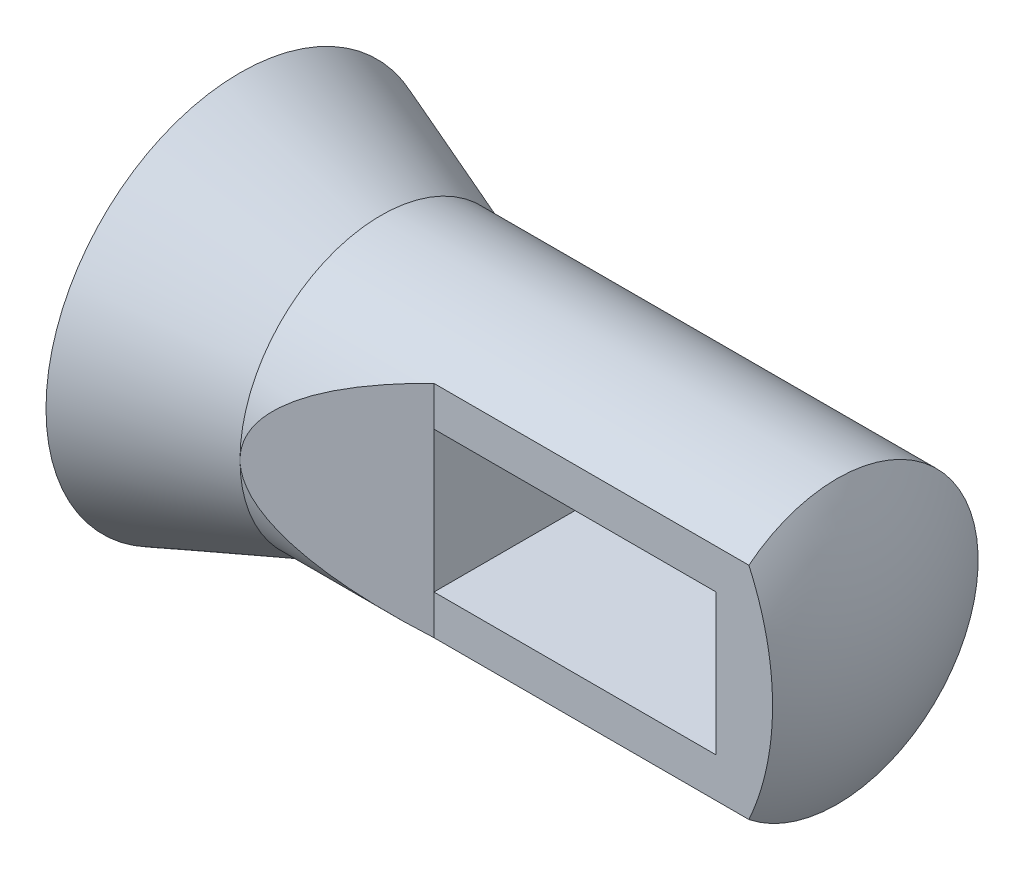
from build123d import *

# Parameters (mm, degrees)
CUT_EXTRUDE2_DEPTH      = 35.925
CUT_EXTRUDE2_DEPTH_BACK = 35.925
SKETCH4_W               = 50.8
SKETCH4_H               = 25.4
CUT_EXTRUDE3_DEPTH      = 51.8


with BuildPart() as part:
    # Sketch1 → Revolve1 (revolve)
    with BuildSketch(Plane.XY):
        with BuildLine():
            Line((0, 0), (0, 34.925))
            Line((0, 34.925), (25.4, 25.4))
            Line((25.4, 25.4), (107.494090512, 25.4))
            ThreePointArc((107.494090512, 25.4), (112.569031975, 13.148007491), (114.3, 0))
            Line((114.3, 0), (0, 0))
        make_face()
    revolve(axis=Axis((0, 0, 0), (1, 0, 0)))

    # Sketch3 → Cut-Extrude2 (cut, two sides)
    with BuildSketch(Plane(origin=(0, 0, 0), x_dir=(1, 0, 0), z_dir=(0, 1, 0))) as cut_extrude2_sk:
        Polygon((25.4, -25.4), (50.8, -15.875), (114.3, -15.875), (114.3, -25.4), align=None)
    extrude(amount=CUT_EXTRUDE2_DEPTH, mode=Mode.SUBTRACT)
    extrude(cut_extrude2_sk.sketch, amount=-CUT_EXTRUDE2_DEPTH_BACK, mode=Mode.SUBTRACT)

    # Sketch4 → Cut-Extrude3 (cut, through all)
    with BuildSketch(Plane.XY.offset(15.875)):
        with Locations((76.2, 0)):
            Rectangle(SKETCH4_W, SKETCH4_H)
    extrude(amount=-CUT_EXTRUDE3_DEPTH, mode=Mode.SUBTRACT)


solid = part.part
